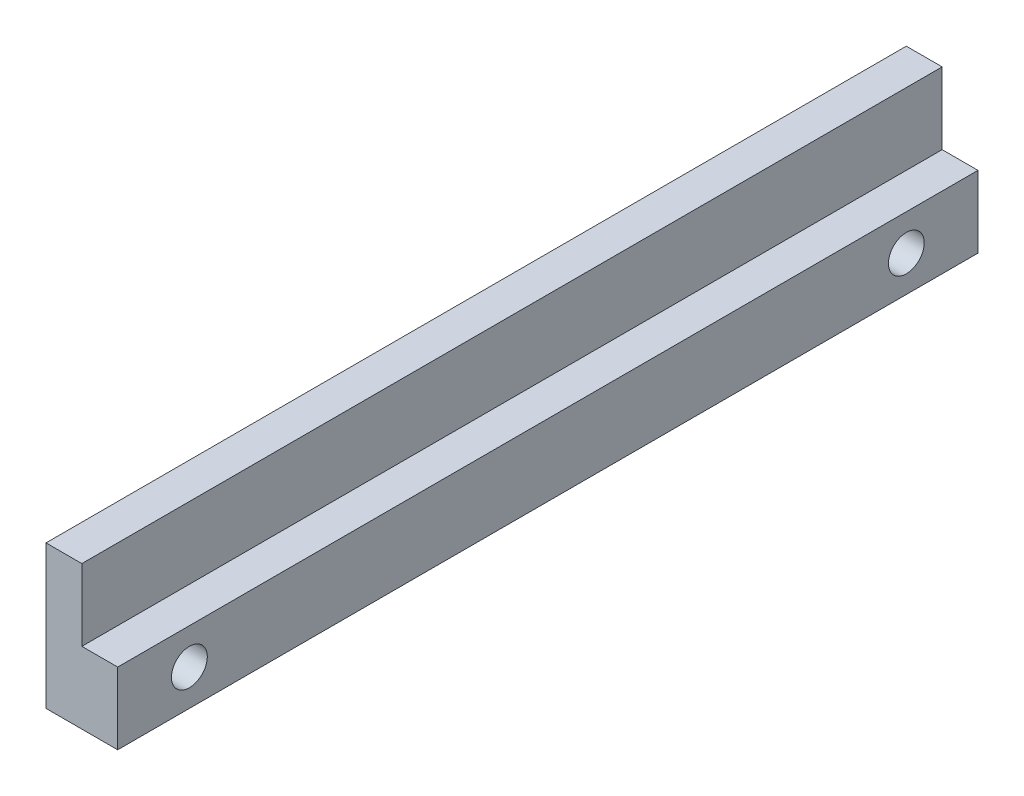
from build123d import *

# Parameters (mm, degrees)
BOSS_EXTRUDE1_DEPTH     = 76.2
SKETCH2_R               = 3.175
CUT_EXTRUDE1_DEPTH      = 1
CUT_EXTRUDE1_DEPTH_BACK = 13.7


with BuildPart() as part:
    # Sketch1 → Boss-Extrude1 (new body, symmetric)
    with BuildSketch(Plane.XY):
        Polygon((0, 12.7), (0, 0), (6.35, 0), (6.35, -12.7), (-6.35, -12.7), (-6.35, 12.7), align=None)
    extrude(amount=BOSS_EXTRUDE1_DEPTH, both=True)

    # Sketch2 → Cut-Extrude1 (cut, two sides)
    with BuildSketch(Plane.ZY.offset(6.35)) as cut_extrude1_sk:
        with Locations((-63.5, -6.35)):
            Circle(SKETCH2_R)
        with Locations((63.5, -6.35)):
            Circle(SKETCH2_R)
    extrude(amount=CUT_EXTRUDE1_DEPTH, mode=Mode.SUBTRACT)
    extrude(cut_extrude1_sk.sketch, amount=-CUT_EXTRUDE1_DEPTH_BACK, mode=Mode.SUBTRACT)


solid = part.part
